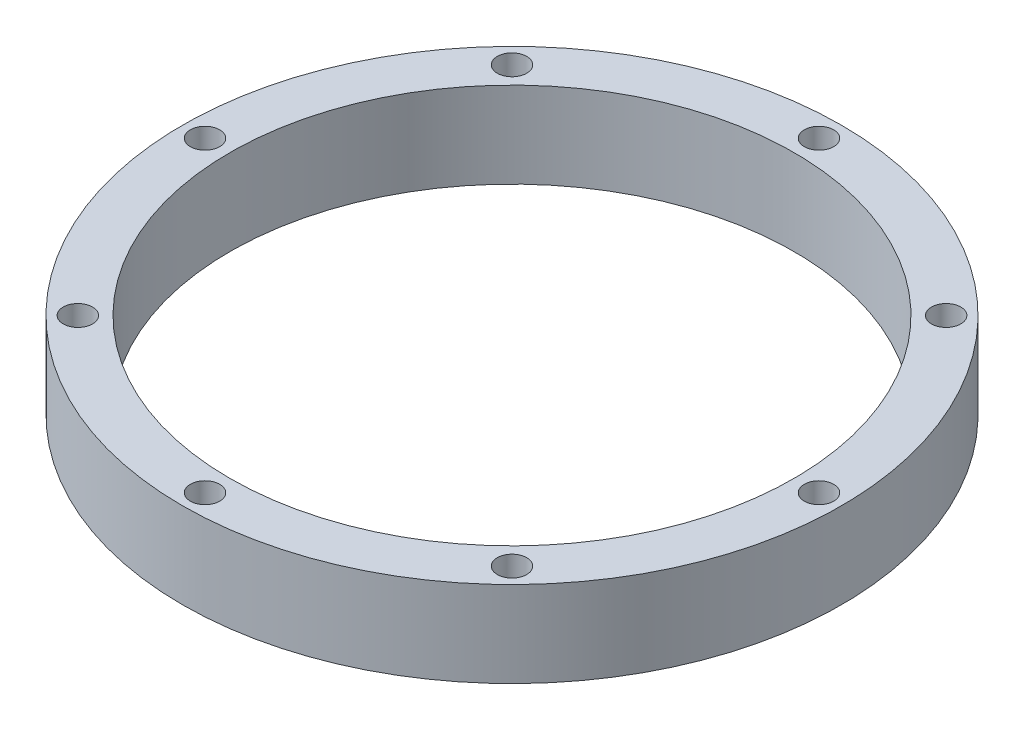
from build123d import *

# Parameters (mm, degrees)
SKETCH1_R           = 73
SKETCH1_R_2         = 62.5
SKETCH1_R_3         = 3.25
BOSS_EXTRUDE1_DEPTH = 19


with BuildPart() as part:
    # Sketch1 → Boss-Extrude1 (new body)
    with BuildSketch(Plane(origin=(0, 0, 0), x_dir=(1, 0, 0), z_dir=(0, 1, 0))):
        Circle(SKETCH1_R)
        Circle(SKETCH1_R_2, mode=Mode.SUBTRACT)
        with Locations((-48.083261121, 48.083261121)):
            Circle(SKETCH1_R_3, mode=Mode.SUBTRACT)
        with Locations((-68, 0)):
            Circle(SKETCH1_R_3, mode=Mode.SUBTRACT)
        with Locations((0, 68)):
            Circle(SKETCH1_R_3, mode=Mode.SUBTRACT)
        with Locations((48.083261121, 48.083261121)):
            Circle(SKETCH1_R_3, mode=Mode.SUBTRACT)
        with Locations((68, 0)):
            Circle(SKETCH1_R_3, mode=Mode.SUBTRACT)
        with Locations((48.083261121, -48.083261121)):
            Circle(SKETCH1_R_3, mode=Mode.SUBTRACT)
        with Locations((0, -68)):
            Circle(SKETCH1_R_3, mode=Mode.SUBTRACT)
        with Locations((-48.083261121, -48.083261121)):
            Circle(SKETCH1_R_3, mode=Mode.SUBTRACT)
    extrude(amount=BOSS_EXTRUDE1_DEPTH)


solid = part.part
